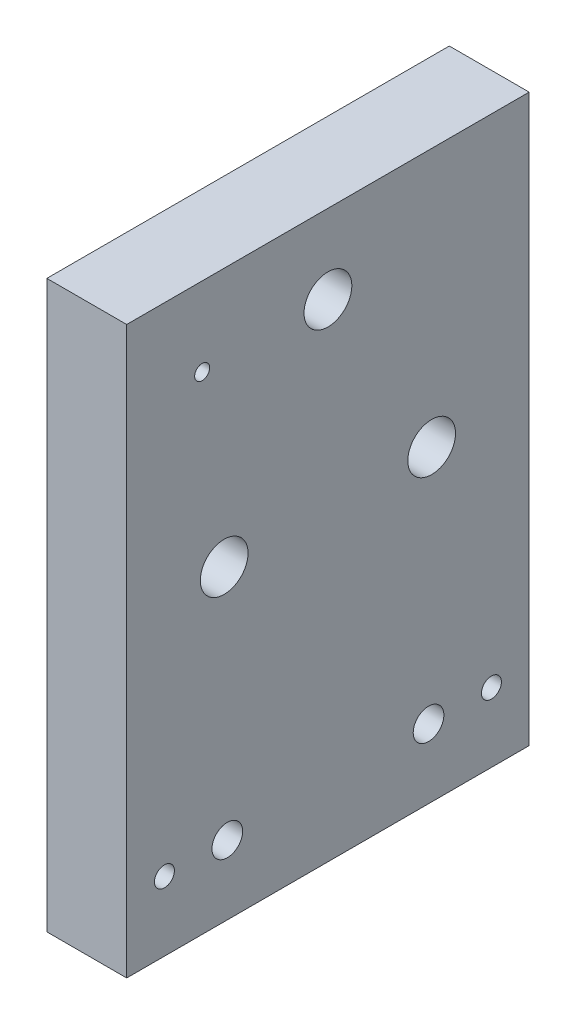
from build123d import *

# Parameters (mm, degrees)
SKETCH26_W                                          = 6.35
SKETCH26_H                                          = 32
BOSS_EXTRUDE2_DEPTH                                 = 45
CUT_EXTRUDE7_REACH                                  = 8.35
SKETCH27_R                                          = 1.595
CBORE_FOR_6_BINDING_HEAD_MACHINE_SCREW1_D           = 3.7973
CBORE_FOR_6_BINDING_HEAD_MACHINE_SCREW1_DEPTH       = 46.5
CBORE_FOR_6_BINDING_HEAD_MACHINE_SCREW1_CBORE_D     = 9.525
CBORE_FOR_6_BINDING_HEAD_MACHINE_SCREW1_CBORE_DEPTH = 1.016
CBORE_FOR_6_BINDING_HEAD_MACHINE_SCREW1_TIP         = 1.140824014
F_0_80_TAPPED_HOLE1_D                               = 1.19126
F_2_CLEARANCE_HOLE1_D                               = 2.4384
F_2_CLEARANCE_HOLE1_DEPTH                           = 20.32
F_2_CLEARANCE_HOLE1_TIP                             = 0.732569267
F_1_16_0_0625_DOWEL_HOLE1_D                         = 1.5875
F_1_16_0_0625_DOWEL_HOLE1_DEPTH                     = 3.523066884
F_1_16_0_0625_DOWEL_HOLE1_TIP                       = 0.476933116


with BuildPart() as part:
    # Sketch26 → Boss-Extrude2 (new body)
    with BuildSketch(Plane(origin=(0, 0, 0), x_dir=(-1, 0, 0), z_dir=(0, 1, 0))):
        with Locations((-3.175, 16)):
            Rectangle(SKETCH26_W, SKETCH26_H)
    extrude(amount=BOSS_EXTRUDE2_DEPTH)

    # Sketch27 → Cut-Extrude7 (cut, up to next)
    with BuildSketch(Plane.ZY, mode=Mode.PRIVATE) as cut_extrude7_sk1:
        with Locations((16, 38.725)):
            Circle(SKETCH27_R)
    cut_extrude7_tool1 = extrude(cut_extrude7_sk1.sketch, amount=-CUT_EXTRUDE7_REACH, mode=Mode.PRIVATE) & part.part
    add(cut_extrude7_tool1.solids().sort_by_distance((0, 38.725, 16))[0], mode=Mode.SUBTRACT)
    # Sketch27 → Cut-Extrude7 (cut, up to next)
    with BuildSketch(Plane.ZY, mode=Mode.PRIVATE) as cut_extrude7_sk2:
        with Locations((24.248891971, 24.4375)):
            Circle(SKETCH27_R)
    cut_extrude7_tool2 = extrude(cut_extrude7_sk2.sketch, amount=-CUT_EXTRUDE7_REACH, mode=Mode.PRIVATE) & part.part
    add(cut_extrude7_tool2.solids().sort_by_distance((0, 24.4375, 24.248892))[0], mode=Mode.SUBTRACT)
    # Sketch27 → Cut-Extrude7 (cut, up to next)
    with BuildSketch(Plane.ZY, mode=Mode.PRIVATE) as cut_extrude7_sk3:
        with Locations((7.751108029, 24.4375)):
            Circle(SKETCH27_R)
    cut_extrude7_tool3 = extrude(cut_extrude7_sk3.sketch, amount=-CUT_EXTRUDE7_REACH, mode=Mode.PRIVATE) & part.part
    add(cut_extrude7_tool3.solids().sort_by_distance((0, 24.4375, 7.751108))[0], mode=Mode.SUBTRACT)

    # CBORE for #6 Binding Head Machine Screw1
    with Locations(Plane.ZY):
        with Locations((16, 38.725), (24.248891971, 24.4375), (7.751108029, 24.4375)):
            CounterBoreHole(CBORE_FOR_6_BINDING_HEAD_MACHINE_SCREW1_D / 2, CBORE_FOR_6_BINDING_HEAD_MACHINE_SCREW1_CBORE_D / 2, CBORE_FOR_6_BINDING_HEAD_MACHINE_SCREW1_CBORE_DEPTH, depth=CBORE_FOR_6_BINDING_HEAD_MACHINE_SCREW1_DEPTH)
            with Locations((0, 0, -(CBORE_FOR_6_BINDING_HEAD_MACHINE_SCREW1_DEPTH + CBORE_FOR_6_BINDING_HEAD_MACHINE_SCREW1_TIP / 2))):  # 118° drill point
                Cone(0, CBORE_FOR_6_BINDING_HEAD_MACHINE_SCREW1_D / 2, CBORE_FOR_6_BINDING_HEAD_MACHINE_SCREW1_TIP, mode=Mode.SUBTRACT)

    # #0-80 Tapped Hole1 (through all)
    with Locations(Plane.ZY):
        with Locations((26, 38.725)):
            Hole(F_0_80_TAPPED_HOLE1_D / 2)

    # #2 Clearance Hole1
    with Locations(Plane.ZY):
        with Locations((8, 5.5), (24, 5.5)):
            Hole(F_2_CLEARANCE_HOLE1_D / 2, depth=F_2_CLEARANCE_HOLE1_DEPTH)
            with Locations((0, 0, -(F_2_CLEARANCE_HOLE1_DEPTH + F_2_CLEARANCE_HOLE1_TIP / 2))):  # 118° drill point
                Cone(0, F_2_CLEARANCE_HOLE1_D / 2, F_2_CLEARANCE_HOLE1_TIP, mode=Mode.SUBTRACT)

    # 1/16 (0.0625) Dowel Hole1
    with Locations(Plane(origin=(6.35, 0, 0), x_dir=(0, 0, -1), z_dir=(1, 0, 0))):
        with Locations((-29, 5.5), (-3, 5.5)):
            Hole(F_1_16_0_0625_DOWEL_HOLE1_D / 2, depth=F_1_16_0_0625_DOWEL_HOLE1_DEPTH)
            with Locations((0, 0, -(F_1_16_0_0625_DOWEL_HOLE1_DEPTH + F_1_16_0_0625_DOWEL_HOLE1_TIP / 2))):  # 118° drill point
                Cone(0, F_1_16_0_0625_DOWEL_HOLE1_D / 2, F_1_16_0_0625_DOWEL_HOLE1_TIP, mode=Mode.SUBTRACT)


solid = part.part
